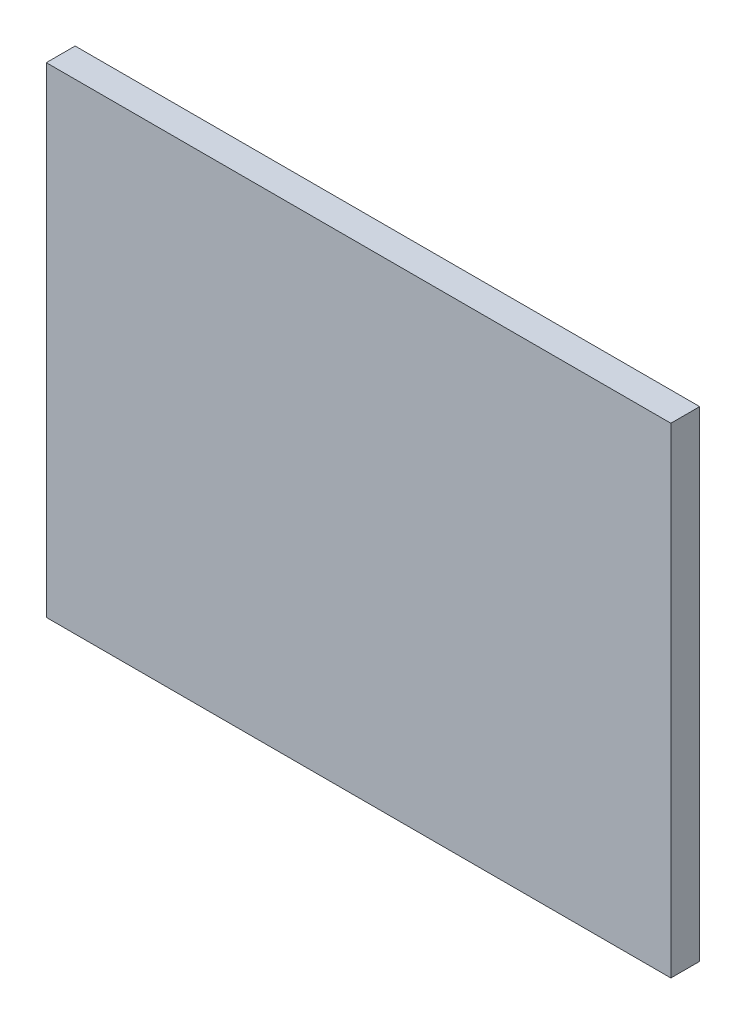
from build123d import *

# Parameters (mm, degrees)
SKETCH1_W           = 65
SKETCH1_H           = 50
BOSS_EXTRUDE1_DEPTH = 3


with BuildPart() as part:
    # Sketch1 → Boss-Extrude1 (new body)
    with BuildSketch(Plane.XY):
        with Locations((-32.5, 25)):
            Rectangle(SKETCH1_W, SKETCH1_H)
    extrude(amount=BOSS_EXTRUDE1_DEPTH)


solid = part.part
